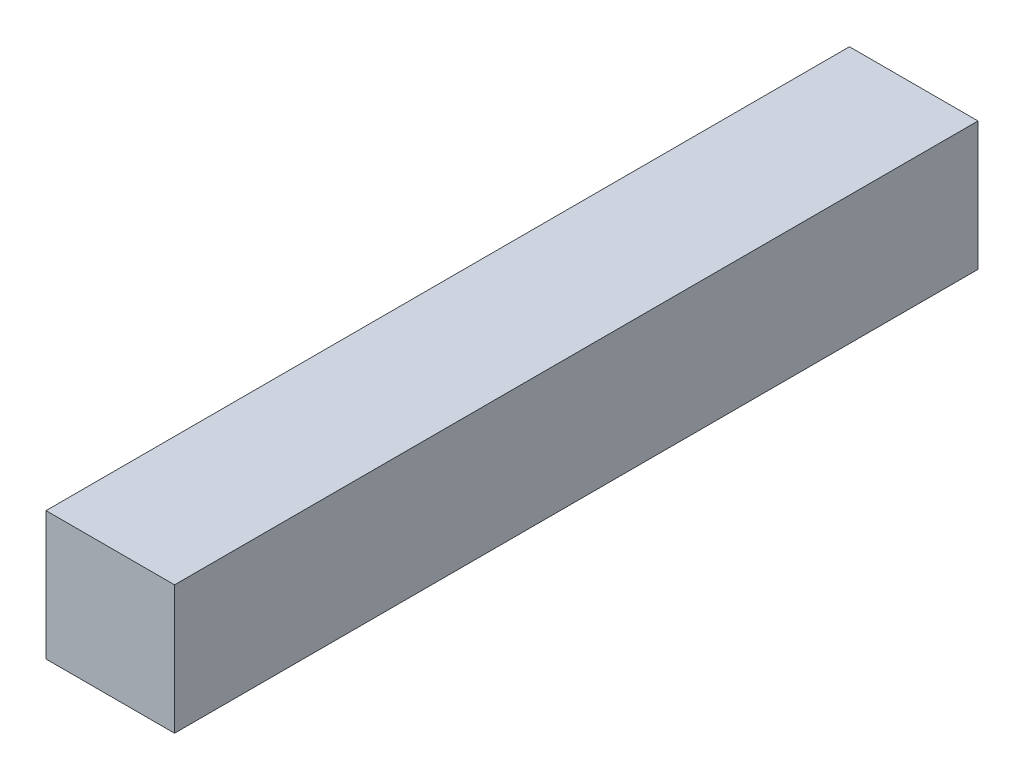
from build123d import *

# Parameters (mm, degrees)
SKETCH1_W           = 2
SKETCH1_H           = 12.5
BOSS_EXTRUDE1_DEPTH = 2


with BuildPart() as part:
    # Sketch1 → Boss-Extrude1 (new body)
    with BuildSketch(Plane(origin=(0, 0, 0), x_dir=(1, 0, 0), z_dir=(0, 1, 0))):
        Rectangle(SKETCH1_W, SKETCH1_H)
    extrude(amount=BOSS_EXTRUDE1_DEPTH)


solid = part.part
